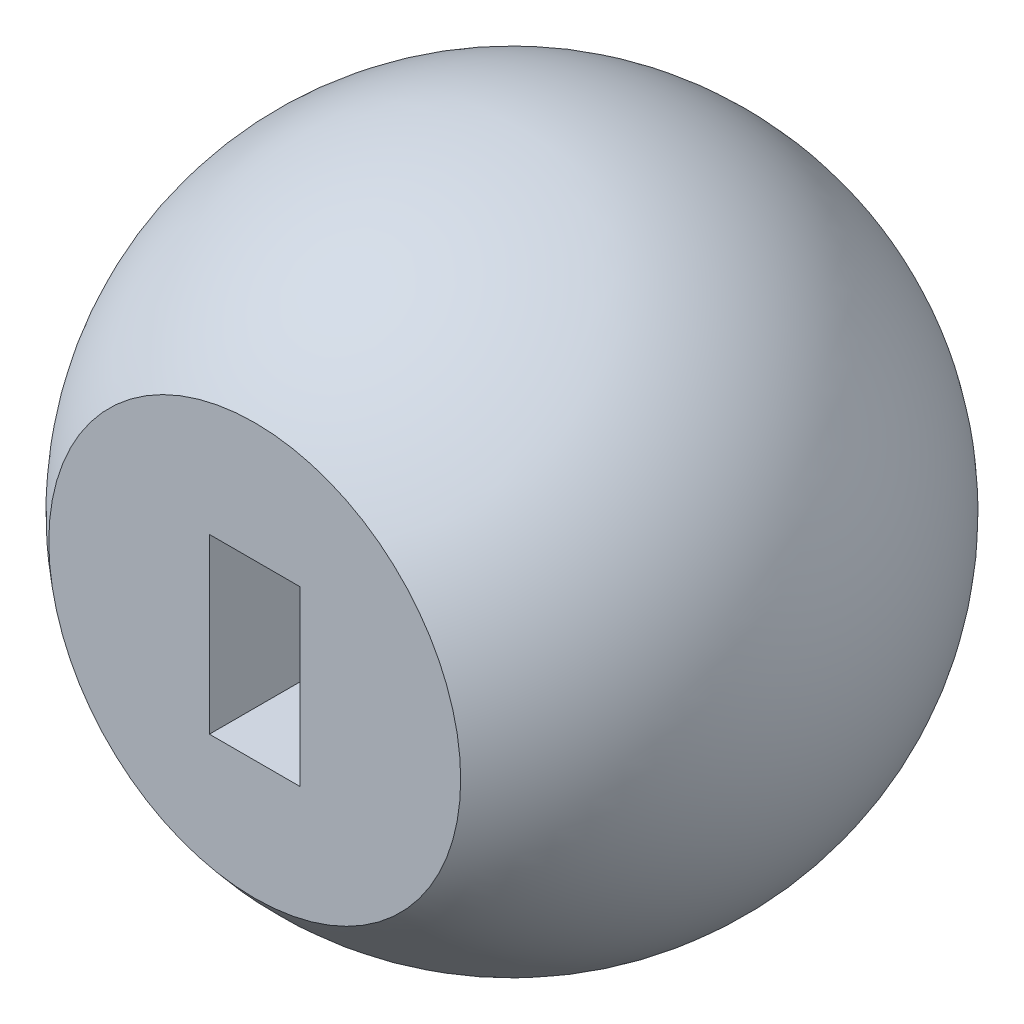
from build123d import *

# Parameters (mm, degrees)
SKETCH_2_W          = 2.2
SKETCH_2_H          = 4.2
CUT_EXTRUDE_1_DEPTH = 4.2


with BuildPart() as part:
    # 草图1 → 旋转2 (revolve)
    with BuildSketch(Plane(origin=(0, 0, 0), x_dir=(1, 0, 0), z_dir=(0, 1, 0))):
        with BuildLine():
            Line((-5, -6.244997998), (0, -6.244997998))
            Line((0, -6.244997998), (0, 8))
            ThreePointArc((0, 8), (-7.548509256, 2.649529771), (-5, -6.244997998))
        make_face()
    revolve(axis=Axis((0, 0, 6.244997998), (0, 0, -1)))

    # 草图2 → 切除-拉伸1 (cut)
    with BuildSketch(Plane.XY.offset(6.244997998)):
        Rectangle(SKETCH_2_W, SKETCH_2_H)
    extrude(amount=-CUT_EXTRUDE_1_DEPTH, mode=Mode.SUBTRACT)


solid = part.part
